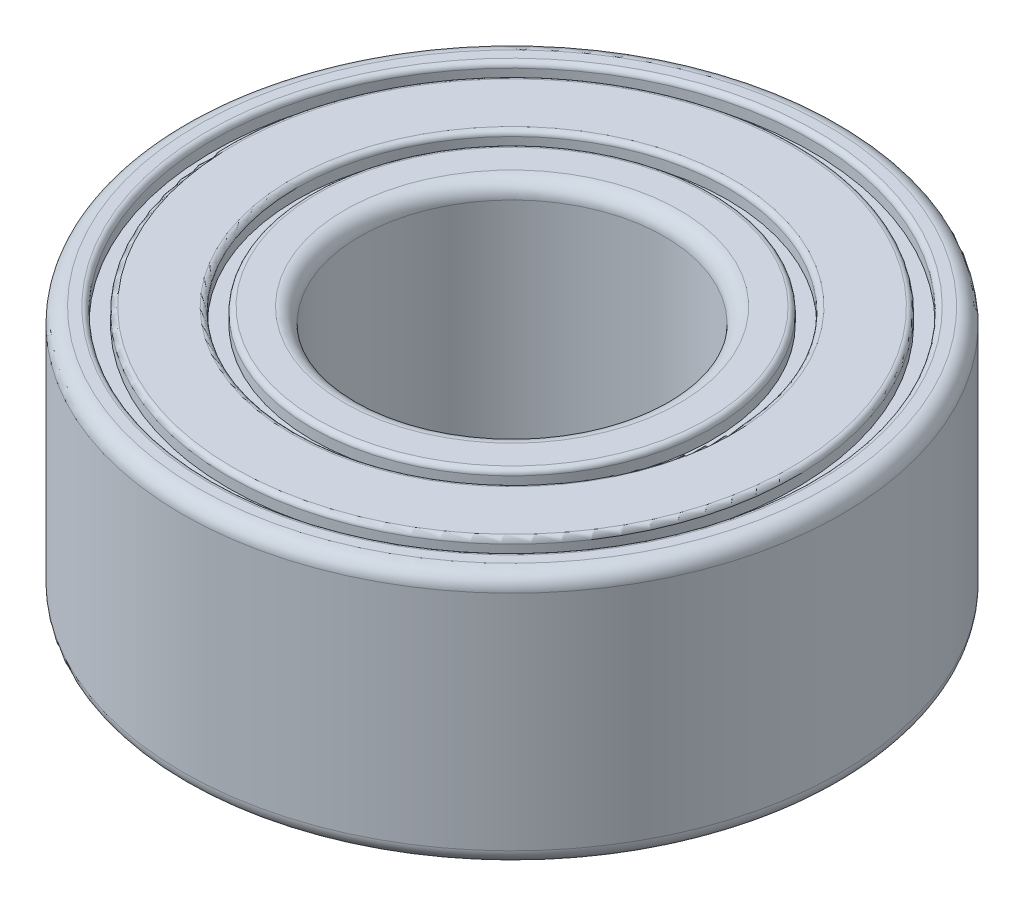
from build123d import *

# Parameters (mm, degrees)
SKETCH1_R           = 6.5
BOSS_EXTRUDE1_DEPTH = 5
CUT_EXTRUDE1_REACH  = 12.464
SKETCH2_R           = 3
SKETCH3_R           = 5.9
SKETCH3_R_2         = 5.6
SKETCH3_R_3         = 4.25
SKETCH3_R_4         = 3.95
CUT_EXTRUDE2_DEPTH  = 0.3
SKETCH4_R           = 5.9
SKETCH4_R_2         = 5.6
SKETCH4_R_3         = 4.25
SKETCH4_R_4         = 3.95
CUT_EXTRUDE3_DEPTH  = 0.3
FILLET1_R           = 0.1
FILLET2_R           = 0.3


with BuildPart() as part:
    # Sketch1 → Boss-Extrude1 (new body)
    with BuildSketch(Plane(origin=(0, 0, 0), x_dir=(1, 0, 0), z_dir=(0, 1, 0))):
        with Locations(Location((0, 0, 0), (0, 0, 270))):
            Circle(SKETCH1_R)
    extrude(amount=BOSS_EXTRUDE1_DEPTH)

    # Sketch2 → Cut-Extrude1 (cut, up to next)
    with BuildSketch(Plane(origin=(0, 5, 0), x_dir=(1, 0, 0), z_dir=(0, 1, 0)), mode=Mode.PRIVATE) as cut_extrude1_sk1:
        with Locations(Location((0, 0, 0), (0, 0, 270))):
            Circle(SKETCH2_R)
    cut_extrude1_tool1 = extrude(cut_extrude1_sk1.sketch, amount=-CUT_EXTRUDE1_REACH, mode=Mode.PRIVATE) & part.part
    add(cut_extrude1_tool1.solids().sort_by_distance((0, 5, 0))[0], mode=Mode.SUBTRACT)

    # Sketch3 → Cut-Extrude2 (cut)
    with BuildSketch(Plane(origin=(0, 5, 0), x_dir=(1, 0, 0), z_dir=(0, 1, 0))):
        with Locations(Location((0, 0, 0), (0, 0, 270))):
            Circle(SKETCH3_R)
        with Locations(Location((0, 0, 0), (0, 0, 270))):
            Circle(SKETCH3_R_2, mode=Mode.SUBTRACT)
        with Locations(Location((0, 0, 0), (0, 0, 270))):
            Circle(SKETCH3_R_3)
        with Locations(Location((0, 0, 0), (0, 0, 270))):
            Circle(SKETCH3_R_4, mode=Mode.SUBTRACT)
    extrude(amount=-CUT_EXTRUDE2_DEPTH, mode=Mode.SUBTRACT)

    # Sketch4 → Cut-Extrude3 (cut)
    with BuildSketch(Plane.XZ):
        with Locations(Location((0, 0, 0), (0, 0, 90))):
            Circle(SKETCH4_R)
        with Locations(Location((0, 0, 0), (0, 0, 90))):
            Circle(SKETCH4_R_2, mode=Mode.SUBTRACT)
        with Locations(Location((0, 0, 0), (0, 0, 90))):
            Circle(SKETCH4_R_3)
        with Locations(Location((0, 0, 0), (0, 0, 90))):
            Circle(SKETCH4_R_4, mode=Mode.SUBTRACT)
    extrude(amount=-CUT_EXTRUDE3_DEPTH, mode=Mode.SUBTRACT)

    # Fillet1
    fillet1_edges = [part.edges().sort_by_distance(p)[0] for p in [
        (0, 5, -3.95),
        (0, 5, -4.25),
        (0, 5, -5.6),
        (0, 5, -5.9),
        (0, 0, -5.6),
        (0, 0, -5.9),
        (0, 0, -3.95),
        (0, 0, -4.25),
    ]]
    fillet(fillet1_edges, radius=FILLET1_R)

    # Fillet2
    fillet2_edges = [part.edges().sort_by_distance(p)[0] for p in [
        (0, 0, -6.5),
        (0, 5, -6.5),
        (0, 5, -3),
        (0, 0, -3),
    ]]
    fillet(fillet2_edges, radius=FILLET2_R)


solid = part.part
